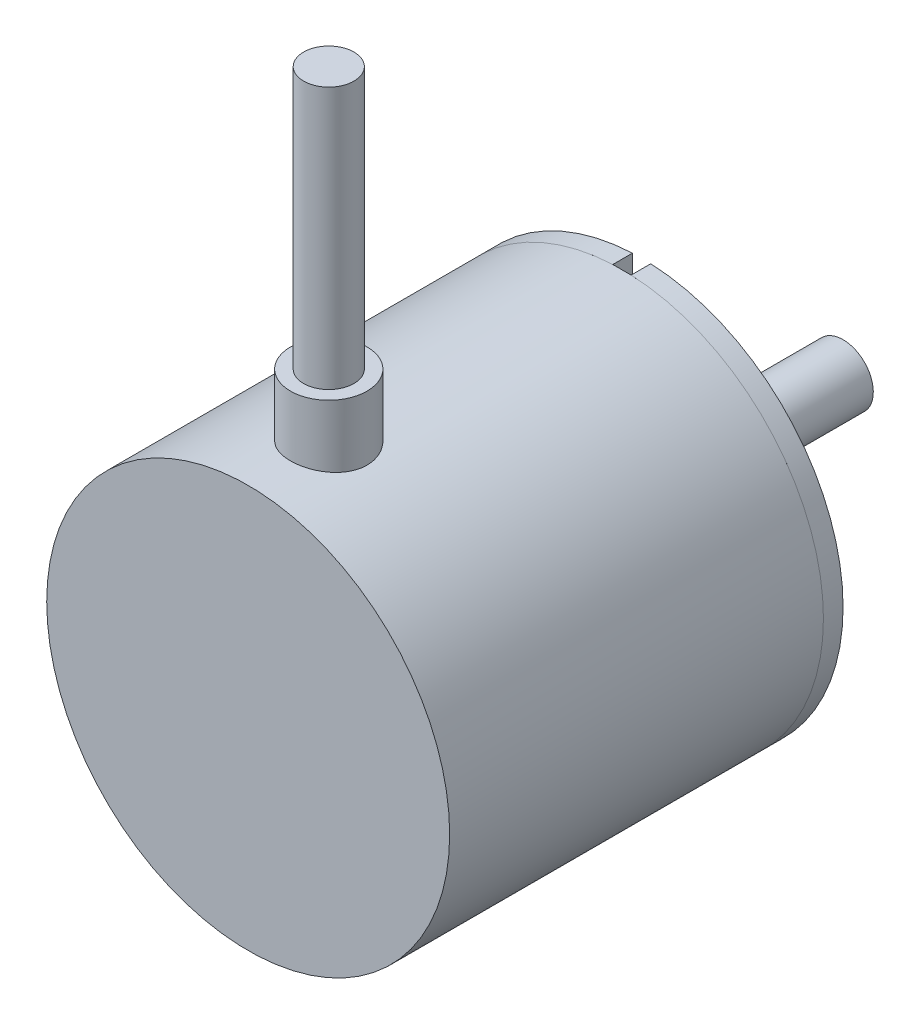
from build123d import *

# Parameters (mm, degrees)
SKETCH1_R           = 20
BOSS_EXTRUDE1_DEPTH = 1.95
SKETCH2_R           = 10
BOSS_EXTRUDE2_DEPTH = 5
SKETCH3_R           = 3
BOSS_EXTRUDE3_DEPTH = 15
SKETCH4_R           = 1
CUT_EXTRUDE1_DEPTH  = 10
CUT_EXTRUDE2_DEPTH  = 2.3
SKETCH6_R           = 20
BOSS_EXTRUDE5_DEPTH = 37.1
SKETCH7_R           = 7.5
CUT_EXTRUDE3_DEPTH  = 0.1
SKETCH9_R           = 3.8
BOSS_EXTRUDE6_DEPTH = 26
SKETCH10_R          = 2.5
BOSS_EXTRUDE7_DEPTH = 26
SKETCH11_W          = 6.12779924
SKETCH11_H          = 1.319674488
CUT_EXTRUDE4_DEPTH  = 9


with BuildPart() as part:
    # Sketch1 → Boss-Extrude1 (new body)
    with BuildSketch(Plane.XY):
        Circle(SKETCH1_R)
    extrude(amount=BOSS_EXTRUDE1_DEPTH)

    # Sketch2 → Boss-Extrude2 (add)
    with BuildSketch(Plane(origin=(0, 0, 0), x_dir=(-1, 0, 0), z_dir=(0, 0, -1))):
        Circle(SKETCH2_R)
    extrude(amount=BOSS_EXTRUDE2_DEPTH)

    # Sketch3 → Boss-Extrude3 (add)
    with BuildSketch(Plane(origin=(0, 0, -5), x_dir=(-1, 0, 0), z_dir=(0, 0, -1))):
        Circle(SKETCH3_R)
    extrude(amount=BOSS_EXTRUDE3_DEPTH)

    # Sketch4 → Cut-Extrude1 (cut)
    with BuildSketch(Plane(origin=(0, 0, 0), x_dir=(-1, 0, 0), z_dir=(0, 0, -1))):
        with Locations((0, 15)):
            Circle(SKETCH4_R)
        with Locations((12.990381057, -7.5)):
            Circle(SKETCH4_R)
        with Locations((-12.990381057, -7.5)):
            Circle(SKETCH4_R)
    extrude(amount=-CUT_EXTRUDE1_DEPTH, mode=Mode.SUBTRACT)

    # Sketch5 → Cut-Extrude2 (cut)
    with BuildSketch(Plane(origin=(0, 0, 0), x_dir=(-1, 0, 0), z_dir=(0, 0, -1))):
        with BuildLine():
            ThreePointArc((0.91, 19.979286774), (0.455117852, 19.994821023), (0, 20))
            Line((0, 20), (0, 18.079462351))
            Line((0, 18.079462351), (0.91, 18.079462351))
            Line((0.91, 18.079462351), (0.91, 19.979286774))
        make_face()
        with BuildLine():
            Line((0, 18.079462351), (0, 20))
            ThreePointArc((0, 20), (-0.455117852, 19.994821023), (-0.91, 19.979286774))
            Line((-0.91, 19.979286774), (-0.91, 18.079462351))
            Line((-0.91, 18.079462351), (0, 18.079462351))
        make_face()
    extrude(amount=-CUT_EXTRUDE2_DEPTH, mode=Mode.SUBTRACT)

    # Sketch7 → Cut-Extrude3 (cut)
    with BuildSketch(Plane(origin=(0, 0, -5), x_dir=(-1, 0, 0), z_dir=(0, 0, -1))):
        Circle(SKETCH7_R)
    extrude(amount=-CUT_EXTRUDE3_DEPTH, mode=Mode.SUBTRACT)

    # Sketch11 → Cut-Extrude4 (cut)
    with BuildSketch(Plane(origin=(0, 0, -20), x_dir=(-1, 0, 0), z_dir=(0, 0, -1))):
        with Locations((0.136461737, -2.659837244)):
            Rectangle(SKETCH11_W, SKETCH11_H)
    extrude(amount=-CUT_EXTRUDE4_DEPTH, mode=Mode.SUBTRACT)


with BuildPart() as body_2:
    # Sketch6 → Boss-Extrude5 (new body)
    with BuildSketch(Plane.XY.offset(1.95)):
        Circle(SKETCH6_R)
    extrude(amount=BOSS_EXTRUDE5_DEPTH)

    # Sketch9 → Boss-Extrude6 (add)
    with BuildSketch(Plane(origin=(0, 0, 0), x_dir=(1, 0, 0), z_dir=(0, 1, 0))):
        with Locations((0, -31.05)):
            Circle(SKETCH9_R)
    extrude(amount=BOSS_EXTRUDE6_DEPTH)

    # Sketch10 → Boss-Extrude7 (add)
    with BuildSketch(Plane(origin=(0, 26, 0), x_dir=(1, 0, 0), z_dir=(0, 1, 0))):
        with Locations((0, -31.05)):
            Circle(SKETCH10_R)
    extrude(amount=BOSS_EXTRUDE7_DEPTH)


solid = Compound([part.part, body_2.part])
